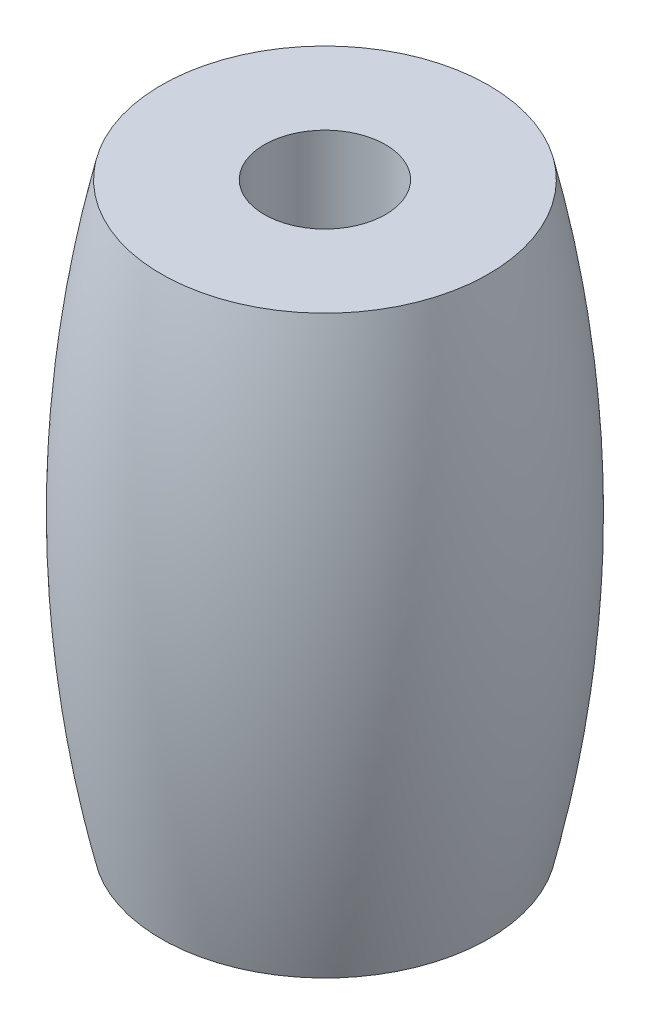
from build123d import *


with BuildPart() as part:
    # Croquis1 → Revolución2 (revolve)
    with BuildSketch(Plane.XY):
        with BuildLine():
            Line((2, 19), (2, 0))
            Line((2, 0), (5.4, 0))
            add(Edge.make_bspline(
                [(5.4, 19), (7.6, 9.5), (5.4, 0)],
                knots=[0, 0, 0, 1, 1, 1], degree=2))
            Line((5.4, 19), (2, 19))
        make_face()
    revolve(axis=Axis((0, 0, 0), (0, 1, 0)))


solid = part.part
